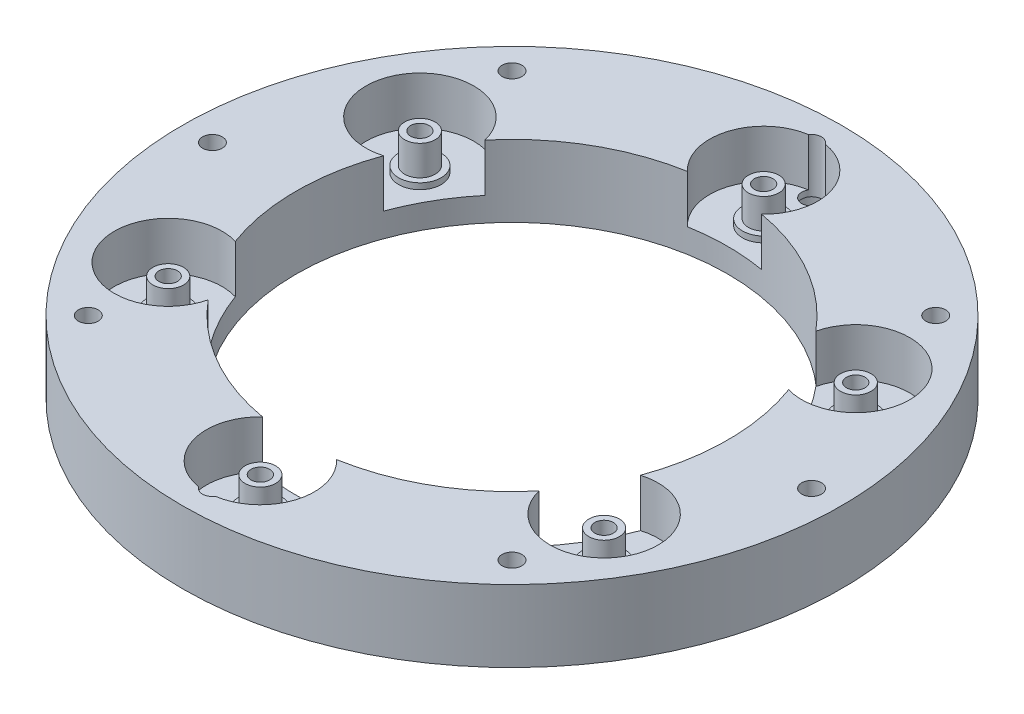
from build123d import *

# Parameters (mm, degrees)
SKETCH1_R           = 55
SKETCH1_R_2         = 36
SKETCH1_R_3         = 1.55
BOSS_EXTRUDE1_DEPTH = 4
SKETCH3_R           = 3.55
SKETCH3_R_2         = 1.55
BOSS_EXTRUDE2_DEPTH = 1
SKETCH5_R           = 2.55
SKETCH5_R_2         = 1.55
BOSS_EXTRUDE3_DEPTH = 5
SKETCH6_R           = 55
BOSS_EXTRUDE4_DEPTH = 8
SKETCH8_R           = 1.65
CUT_EXTRUDE2_DEPTH  = 13
SKETCH7_R           = 3.55
SKETCH7_R_2         = 1.55
SKETCH7_R_3         = 3.65
SKETCH7_R_4         = 1.65
CUT_EXTRUDE1_DEPTH  = 3


with BuildPart() as part:
    # Sketch1 → Boss-Extrude1 (new body)
    with BuildSketch(Plane(origin=(0, 0, 0), x_dir=(1, 0, 0), z_dir=(0, 1, 0))):
        Circle(SKETCH1_R)
        Circle(SKETCH1_R_2, mode=Mode.SUBTRACT)
        with Locations((0, 42)):
            Circle(SKETCH1_R_3, mode=Mode.SUBTRACT)
        with Locations((36.373066959, 21)):
            Circle(SKETCH1_R_3, mode=Mode.SUBTRACT)
        with Locations((36.373066959, -21)):
            Circle(SKETCH1_R_3, mode=Mode.SUBTRACT)
        with Locations((0, -42)):
            Circle(SKETCH1_R_3, mode=Mode.SUBTRACT)
        with Locations((-36.373066959, -21)):
            Circle(SKETCH1_R_3, mode=Mode.SUBTRACT)
        with Locations((-36.373066959, 21)):
            Circle(SKETCH1_R_3, mode=Mode.SUBTRACT)
    extrude(amount=BOSS_EXTRUDE1_DEPTH)

    # Sketch3 → Boss-Extrude2 (add)
    with BuildSketch(Plane(origin=(0, 4, 0), x_dir=(1, 0, 0), z_dir=(0, 1, 0))):
        with Locations((-36.373066959, 21)):
            Circle(SKETCH3_R)
        with Locations((-36.373066959, 21)):
            Circle(SKETCH3_R_2, mode=Mode.SUBTRACT)
        with Locations((0, -42)):
            Circle(SKETCH3_R)
        with Locations((0, -42)):
            Circle(SKETCH3_R_2, mode=Mode.SUBTRACT)
        with Locations((36.373066959, 21)):
            Circle(SKETCH3_R)
        with Locations((36.373066959, 21)):
            Circle(SKETCH3_R_2, mode=Mode.SUBTRACT)
        with Locations((0, 42)):
            Circle(SKETCH3_R)
        with Locations((0, 42)):
            Circle(SKETCH3_R_2, mode=Mode.SUBTRACT)
        with Locations((36.373066959, -21)):
            Circle(SKETCH3_R)
        with Locations((36.373066959, -21)):
            Circle(SKETCH3_R_2, mode=Mode.SUBTRACT)
        with Locations((-36.373066959, -21)):
            Circle(SKETCH3_R)
        with Locations((-36.373066959, -21)):
            Circle(SKETCH3_R_2, mode=Mode.SUBTRACT)
    extrude(amount=BOSS_EXTRUDE2_DEPTH)

    # Sketch5 → Boss-Extrude3 (add)
    with BuildSketch(Plane(origin=(0, 5, 0), x_dir=(1, 0, 0), z_dir=(0, 1, 0))):
        with Locations((-36.373066959, -21)):
            Circle(SKETCH5_R)
        with Locations((-36.373066959, -21)):
            Circle(SKETCH5_R_2, mode=Mode.SUBTRACT)
        with Locations((0, -42)):
            Circle(SKETCH5_R)
        with Locations((0, -42)):
            Circle(SKETCH5_R_2, mode=Mode.SUBTRACT)
        with Locations((36.373066959, -21)):
            Circle(SKETCH5_R)
        with Locations((36.373066959, -21)):
            Circle(SKETCH5_R_2, mode=Mode.SUBTRACT)
        with Locations((36.373066959, 21)):
            Circle(SKETCH5_R)
        with Locations((36.373066959, 21)):
            Circle(SKETCH5_R_2, mode=Mode.SUBTRACT)
        with Locations((0, 42)):
            Circle(SKETCH5_R)
        with Locations((0, 42)):
            Circle(SKETCH5_R_2, mode=Mode.SUBTRACT)
        with Locations((-36.373066959, 21)):
            Circle(SKETCH5_R)
        with Locations((-36.373066959, 21)):
            Circle(SKETCH5_R_2, mode=Mode.SUBTRACT)
    extrude(amount=BOSS_EXTRUDE3_DEPTH)

    # Sketch6 → Boss-Extrude4 (add)
    with BuildSketch(Plane(origin=(0, 4, 0), x_dir=(1, 0, 0), z_dir=(0, 1, 0))):
        Circle(SKETCH6_R)
        with BuildLine():
            ThreePointArc((6.187442022, 35.464285714), (0, 51), (-6.187442022, 35.464285714))
            ThreePointArc((-6.187442022, 35.464285714), (-18, 31.176914536), (-27.619251345, 23.090624833))
            ThreePointArc((-27.619251345, 23.090624833), (-44.167295593, 25.5), (-33.806693367, 12.373660882))
            ThreePointArc((-33.806693367, 12.373660882), (-36, 0), (-33.806693367, -12.373660882))
            ThreePointArc((-33.806693367, -12.373660882), (-44.167295593, -25.5), (-27.619251345, -23.090624833))
            ThreePointArc((-27.619251345, -23.090624833), (-18, -31.176914536), (-6.187442022, -35.464285714))
            ThreePointArc((-6.187442022, -35.464285714), (0, -51), (6.187442022, -35.464285714))
            ThreePointArc((6.187442022, -35.464285714), (18, -31.176914536), (27.619251345, -23.090624833))
            ThreePointArc((27.619251345, -23.090624833), (44.167295593, -25.5), (33.806693367, -12.373660882))
            ThreePointArc((33.806693367, -12.373660882), (36, 0), (33.806693367, 12.373660882))
            ThreePointArc((33.806693367, 12.373660882), (44.167295593, 25.5), (27.619251345, 23.090624833))
            ThreePointArc((27.619251345, 23.090624833), (18, 31.176914536), (6.187442022, 35.464285714))
        make_face(mode=Mode.SUBTRACT)
    extrude(amount=BOSS_EXTRUDE4_DEPTH)

    # Sketch8 → Cut-Extrude2 (cut, through all)
    with BuildSketch(Plane(origin=(0, 12, 0), x_dir=(1, 0, 0), z_dir=(0, 1, 0))):
        with Locations((0, 50)):
            Circle(SKETCH8_R)
        with Locations((35.355339059, 35.355339059)):
            Circle(SKETCH8_R)
        with Locations((50, 0)):
            Circle(SKETCH8_R)
        with Locations((35.355339059, -35.355339059)):
            Circle(SKETCH8_R)
        with Locations((0, -50)):
            Circle(SKETCH8_R)
        with Locations((-35.355339059, -35.355339059)):
            Circle(SKETCH8_R)
        with Locations((-50, 0)):
            Circle(SKETCH8_R)
        with Locations((-35.355339059, 35.355339059)):
            Circle(SKETCH8_R)
    extrude(amount=-CUT_EXTRUDE2_DEPTH, mode=Mode.SUBTRACT)

    # Sketch7 → Cut-Extrude1 (cut)
    with BuildSketch(Plane.XZ):
        with Locations((-36.373066959, -21)):
            Circle(SKETCH7_R)
        with Locations((-36.373066959, -21)):
            Circle(SKETCH7_R_2, mode=Mode.SUBTRACT)
        with Locations((-36.373066959, 21)):
            Circle(SKETCH7_R)
        with Locations((-36.373066959, 21)):
            Circle(SKETCH7_R_2, mode=Mode.SUBTRACT)
        with Locations((0, 42)):
            Circle(SKETCH7_R)
        with Locations((0, 42)):
            Circle(SKETCH7_R_2, mode=Mode.SUBTRACT)
        with Locations((36.373066959, 21)):
            Circle(SKETCH7_R)
        with Locations((36.373066959, 21)):
            Circle(SKETCH7_R_2, mode=Mode.SUBTRACT)
        with Locations((36.373066959, -21)):
            Circle(SKETCH7_R)
        with Locations((36.373066959, -21)):
            Circle(SKETCH7_R_2, mode=Mode.SUBTRACT)
        with Locations((0, -42)):
            Circle(SKETCH7_R)
        with Locations((0, -42)):
            Circle(SKETCH7_R_2, mode=Mode.SUBTRACT)
        with Locations((-35.355339059, -35.355339059)):
            Circle(SKETCH7_R_3)
        with Locations((-35.355339059, -35.355339059)):
            Circle(SKETCH7_R_4, mode=Mode.SUBTRACT)
        with Locations((-50, 0)):
            Circle(SKETCH7_R_3)
        with Locations((-50, 0)):
            Circle(SKETCH7_R_4, mode=Mode.SUBTRACT)
        with Locations((-35.355339059, 35.355339059)):
            Circle(SKETCH7_R_3)
        with Locations((-35.355339059, 35.355339059)):
            Circle(SKETCH7_R_4, mode=Mode.SUBTRACT)
        with Locations((0, 50)):
            Circle(SKETCH7_R_3)
        with Locations((0, 50)):
            Circle(SKETCH7_R_4, mode=Mode.SUBTRACT)
        with Locations((35.355339059, 35.355339059)):
            Circle(SKETCH7_R_3)
        with Locations((35.355339059, 35.355339059)):
            Circle(SKETCH7_R_4, mode=Mode.SUBTRACT)
        with Locations((50, 0)):
            Circle(SKETCH7_R_3)
        with Locations((50, 0)):
            Circle(SKETCH7_R_4, mode=Mode.SUBTRACT)
        with Locations((35.355339059, -35.355339059)):
            Circle(SKETCH7_R_3)
        with Locations((35.355339059, -35.355339059)):
            Circle(SKETCH7_R_4, mode=Mode.SUBTRACT)
        with Locations((0, -50)):
            Circle(SKETCH7_R_3)
        with Locations((0, -50)):
            Circle(SKETCH7_R_4, mode=Mode.SUBTRACT)
    extrude(amount=-CUT_EXTRUDE1_DEPTH, mode=Mode.SUBTRACT)


solid = part.part
